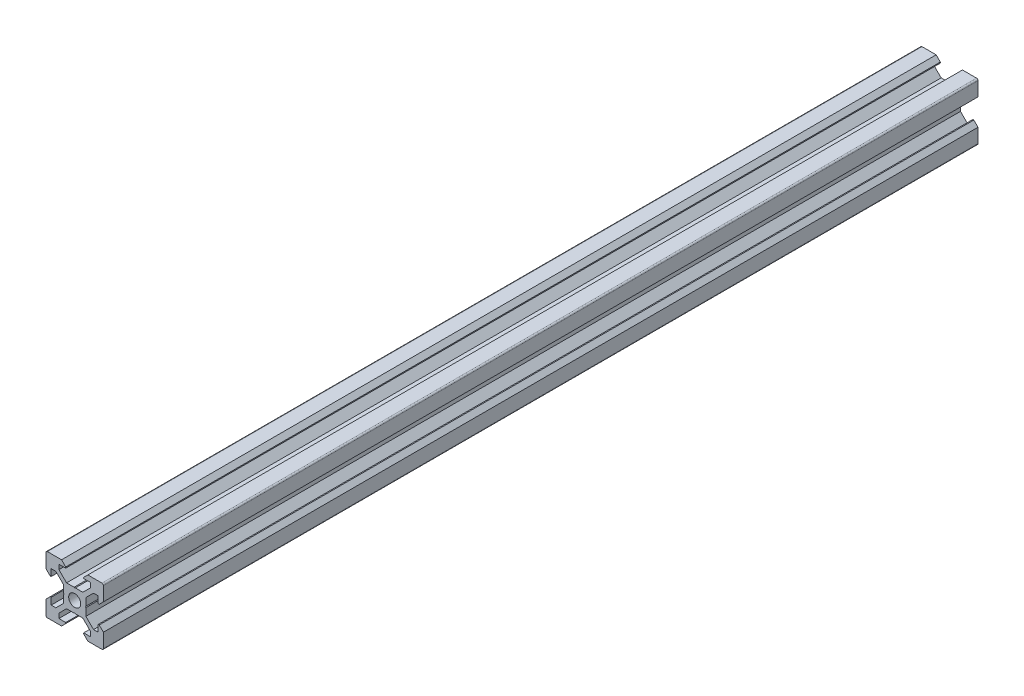
from build123d import *

# Parameters (mm, degrees)
SKETCH1_R           = 2.1
BOSS_EXTRUDE1_DEPTH = 500


with BuildPart() as part:
    # Sketch1 → Boss-Extrude1 (new body)
    with BuildSketch(Plane(origin=(0, 0, 0), x_dir=(-1, 0, 0), z_dir=(0, 0, -1))):
        with BuildLine():
            Line((-3.9, -0.21), (-3.9, -2.839339828))
            Line((-3.9, -2.839339828), (-6.560660172, -5.5))
            Line((-6.560660172, -5.5), (-8.2, -5.5))
            Line((-8.2, -5.5), (-8.2, -3.125))
            Line((-8.2, -3.125), (-8.545, -3.125))
            Line((-8.545, -3.125), (-10, -4.58))
            Line((-10, -4.58), (-10, -9.5))
            ThreePointArc((-10, -9.5), (-9.853553391, -9.853553391), (-9.5, -10))
            Line((-9.5, -10), (-4.58, -10))
            Line((-4.58, -10), (-3.125, -8.545))
            Line((-3.125, -8.545), (-3.125, -8.2))
            Line((-3.125, -8.2), (-5.5, -8.2))
            Line((-5.5, -8.2), (-5.5, -6.560660172))
            Line((-5.5, -6.560660172), (-2.839339828, -3.9))
            Line((-2.839339828, -3.9), (-0.21, -3.9))
            Line((-0.21, -3.9), (0, -3.69))
            Line((0, -3.69), (0.21, -3.9))
            Line((0.21, -3.9), (2.839339828, -3.9))
            Line((2.839339828, -3.9), (5.5, -6.560660172))
            Line((5.5, -6.560660172), (5.5, -8.2))
            Line((5.5, -8.2), (3.125, -8.2))
            Line((3.125, -8.2), (3.125, -8.545))
            Line((3.125, -8.545), (4.58, -10))
            Line((4.58, -10), (9.5, -10))
            ThreePointArc((9.5, -10), (9.853553391, -9.853553391), (10, -9.5))
            Line((10, -9.5), (10, -4.58))
            Line((10, -4.58), (8.545, -3.125))
            Line((8.545, -3.125), (8.2, -3.125))
            Line((8.2, -3.125), (8.2, -5.5))
            Line((8.2, -5.5), (6.560660172, -5.5))
            Line((6.560660172, -5.5), (3.9, -2.839339828))
            Line((3.9, -2.839339828), (3.9, -0.21))
            Line((3.9, -0.21), (3.69, 0))
            Line((3.69, 0), (3.9, 0.21))
            Line((3.9, 0.21), (3.9, 2.839339828))
            Line((3.9, 2.839339828), (6.560660172, 5.5))
            Line((6.560660172, 5.5), (8.2, 5.5))
            Line((8.2, 5.5), (8.2, 3.125))
            Line((8.2, 3.125), (8.545, 3.125))
            Line((8.545, 3.125), (10, 4.58))
            Line((10, 4.58), (10, 9.5))
            ThreePointArc((10, 9.5), (9.853553391, 9.853553391), (9.5, 10))
            Line((9.5, 10), (4.58, 10))
            Line((4.58, 10), (3.125, 8.545))
            Line((3.125, 8.545), (3.125, 8.2))
            Line((3.125, 8.2), (5.5, 8.2))
            Line((5.5, 8.2), (5.5, 6.560660172))
            Line((5.5, 6.560660172), (2.839339828, 3.9))
            Line((2.839339828, 3.9), (0.21, 3.9))
            Line((0.21, 3.9), (0, 3.69))
            Line((0, 3.69), (-0.21, 3.9))
            Line((-0.21, 3.9), (-2.839339828, 3.9))
            Line((-2.839339828, 3.9), (-5.5, 6.560660172))
            Line((-5.5, 6.560660172), (-5.5, 8.2))
            Line((-5.5, 8.2), (-3.125, 8.2))
            Line((-3.125, 8.2), (-3.125, 8.545))
            Line((-3.125, 8.545), (-4.58, 10))
            Line((-4.58, 10), (-9.5, 10))
            ThreePointArc((-9.5, 10), (-9.853553391, 9.853553391), (-10, 9.5))
            Line((-10, 9.5), (-10, 4.58))
            Line((-10, 4.58), (-8.545, 3.125))
            Line((-8.545, 3.125), (-8.2, 3.125))
            Line((-8.2, 3.125), (-8.2, 5.5))
            Line((-8.2, 5.5), (-6.560660172, 5.5))
            Line((-6.560660172, 5.5), (-3.9, 2.839339828))
            Line((-3.9, 2.839339828), (-3.9, 0.21))
            Line((-3.9, 0.21), (-3.69, 0))
            Line((-3.69, 0), (-3.9, -0.21))
        make_face()
        Circle(SKETCH1_R, mode=Mode.SUBTRACT)
    extrude(amount=-BOSS_EXTRUDE1_DEPTH)

    # Split1
    split(bisect_by=Plane.XY.offset(195.2), keep=Keep.TOP)


solid = part.part
